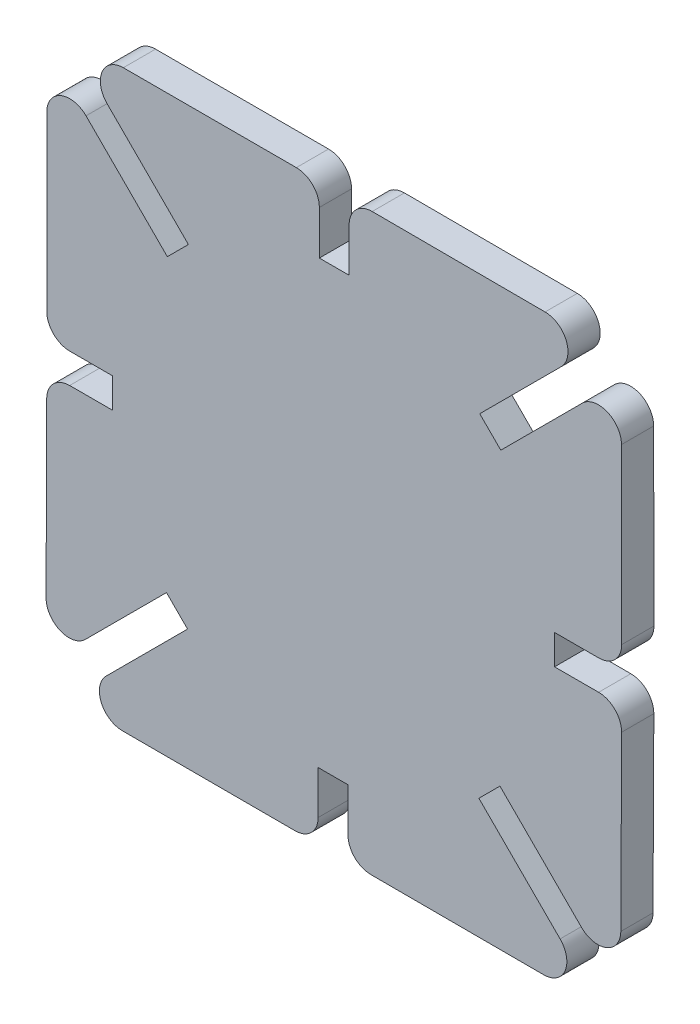
from build123d import *

# Parameters (mm, degrees)
BOSS_EXTRUDE1_DEPTH = 1.4
FILLET1_R           = 2


with BuildPart() as part:
    # Sketch2 → Boss-Extrude1 (new body, symmetric)
    with BuildSketch(Plane.XY):
        Polygon((-23.168593437, 25), (-12.682504049, 14.513910612), (-14.513910612, 12.682504049), (-25, 23.168593437), (-25, 1.325866762), (-19.261635993, 1.325866762), (-19.261635993, -1.264133238), (-25, -1.264133238), (-25.074518955, -23.137726675), (-14.588429567, -12.651637287), (-12.757023004, -14.48304385), (-23.243112392, -24.969133238), (-1.400385717, -25), (-1.400385717, -19.230769231), (1.189614283, -19.230769231), (1.189614283, -25), (23.063207719, -25.043652193), (12.577118332, -14.557562806), (14.408524895, -12.726156242), (24.894614283, -23.21224563), (25, -1.369518955), (19.156250275, -1.369518955), (19.156250275, 1.220481045), (25, 1.220481045), (24.969133238, 23.094074481), (14.48304385, 12.607985094), (12.651637287, 14.439391657), (23.137726675, 24.925481045), (1.295, 25), (1.295, 19.187117037), (-1.295, 19.187117037), (-1.295, 25), align=None)
    extrude(amount=BOSS_EXTRUDE1_DEPTH, both=True)

    # Fillet1
    fillet1_edges = [part.edges().sort_by_distance(p)[0] for p in [
        (-1.295, 25, 0),
        (1.295, 25, 0),
        (23.137726675, 24.925481045, 0),
        (24.969133238, 23.094074481, 0),
        (25, 1.220481045, 0),
        (25, -1.369518955, 0),
        (24.894614283, -23.21224563, 0),
        (23.063207719, -25.043652193, 0),
        (1.189614283, -25, 0),
        (-1.400385717, -25, 0),
        (-23.243112392, -24.969133238, 0),
        (-25.074518955, -23.137726675, 0),
        (-25, -1.264133238, 0),
        (-25, 1.325866762, 0),
        (-25, 23.168593437, 0),
        (-23.168593437, 25, 0),
    ]]
    fillet(fillet1_edges, radius=FILLET1_R)


solid = part.part
